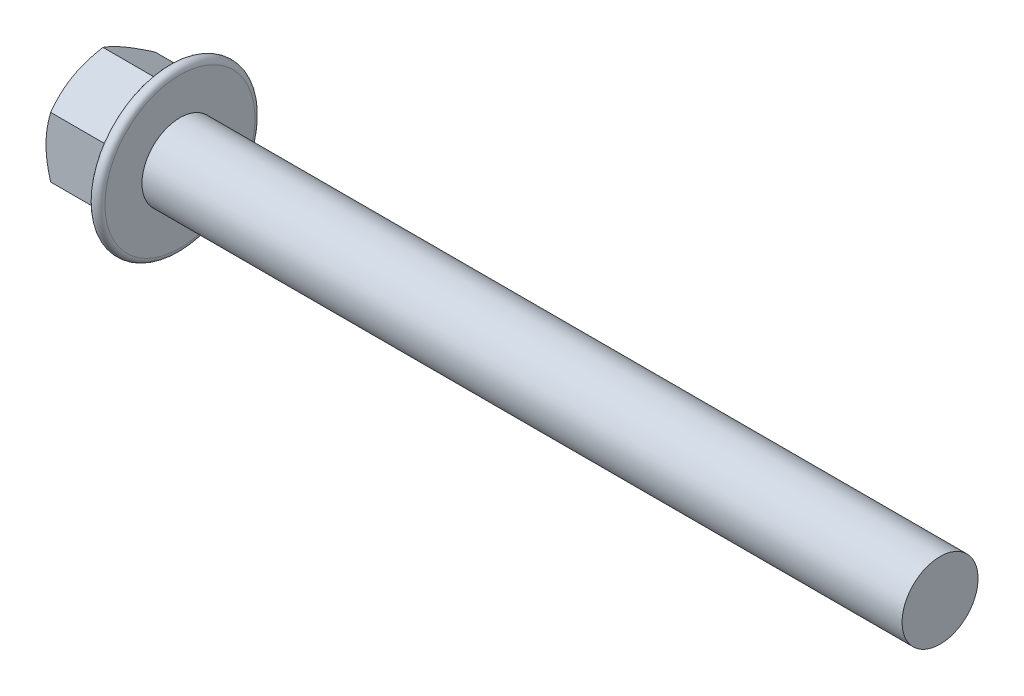
from build123d import *

# Parameters (mm, degrees)
SKETCH2_R         = 3.207274827
HEX_DIE_DEPTH     = 4.3
FLANGEHEXFILLET_R = 0.2
SKETCH4_R         = 2.40625
INDENT_DEPTH      = 0.358333333


with BuildPart() as part:
    # BodySke → Base-Revolve (revolve)
    with BuildSketch(Plane.XY, mode=Mode.PRIVATE) as base_revolve_sk:
        Polygon((4.3, 2), (4.3, 3.17551963), (0.245673873, 3.17551963), (0, 2.75), (0, 0), (44.3, 0), (44.3, 2), align=None)
    revolve(base_revolve_sk.sketch.rotate(Axis((-25.4, 0, 0), (1, 0, 0)), 90), axis=Axis((-25.4, 0, 0), (1, 0, 0)))

    # Sketch2 → Hex-Die (cut)
    with BuildSketch(Plane(origin=(0, 0, 0), x_dir=(0, 0, -1), z_dir=(1, 0, 0))):
        Circle(SKETCH2_R)
        Polygon((-2.75, 1.587713247), (0, 3.175426494), (2.75, 1.587713247), (2.75, -1.587713247), (0, -3.175426494), (-2.75, -1.587713247), align=None, mode=Mode.SUBTRACT)
    extrude(amount=HEX_DIE_DEPTH, mode=Mode.SUBTRACT)

    # Sketch5 → Flange (revolve)
    with BuildSketch(Plane.XY, mode=Mode.PRIVATE) as flange_sk:
        with BuildLine():
            Line((2.243064243, 0), (3.718092214, 4.052606043))
            ThreePointArc((3.718092214, 4.052606043), (4.052094453, 4.245442326), (4.3, 3.95))
            Line((4.3, 3.95), (4.3, 0))
            Line((4.3, 0), (2.243064243, 0))
        make_face()
    revolve(flange_sk.sketch.rotate(Axis((0, 0, 0), (1, 0, 0)), 90), axis=Axis((0, 0, 0), (1, 0, 0)))

    # FlangeHexFillet
    flangehexfillet_edges = [part.edges().sort_by_distance(p)[0] for p in [
        (3.285203168, 0.797319684, 2.75),
        (3.24398239, 2.381569871, 1.375),
        (3.24398239, 2.381569871, -1.375),
        (3.243982387, 0, -2.75),
        (3.24398239, -2.381569871, -1.375),
        (3.24398239, -2.381569871, 1.375),
        (3.285203168, -0.797319684, 2.75),
    ]]
    fillet(flangehexfillet_edges, radius=FLANGEHEXFILLET_R)

    # Sketch4 → Indent (cut)
    with BuildSketch(Plane(origin=(0, 0, 0), x_dir=(0, 0, -1), z_dir=(1, 0, 0))):
        with Locations(Location((0, 0, 0), (0, 0, 180))):
            Circle(SKETCH4_R)
    extrude(amount=INDENT_DEPTH, mode=Mode.SUBTRACT)


solid = part.part
